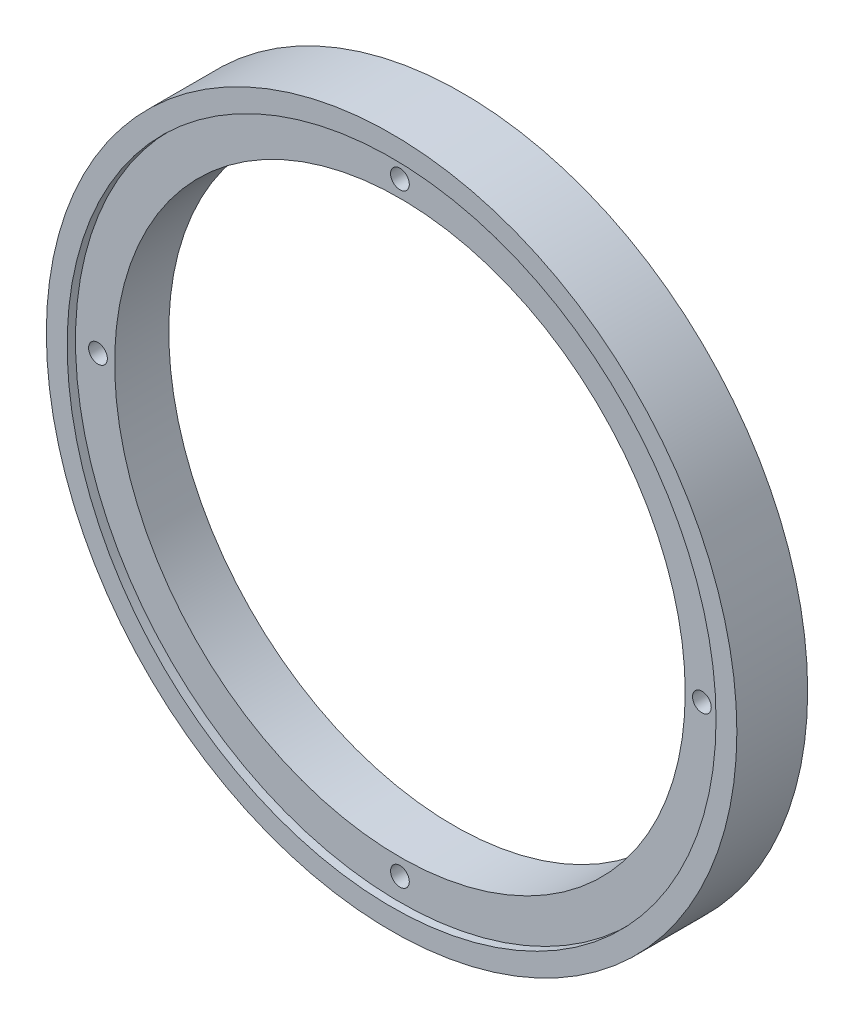
from build123d import *

# Parameters (mm, degrees)
ESQUISSE1_R             = 77.9
ESQUISSE1_R_2           = 2.25
ESQUISSE1_R_3           = 68.5
BOSS_EXTRU_1_DEPTH      = 13
BOSS_EXTRU_2_DEPTH      = 2
BOSS_EXTRU_2_DEPTH_BACK = 15
ESQUISSE2_R             = 82.9
ESQUISSE2_R_2           = 77.9


with BuildPart() as part:
    # Esquisse1 → Boss.-Extru.1 (new body)
    with BuildSketch(Plane.XY):
        Circle(ESQUISSE1_R)
        with Locations((0, -72.5)):
            Circle(ESQUISSE1_R_2, mode=Mode.SUBTRACT)
        with Locations((72.5, 0)):
            Circle(ESQUISSE1_R_2, mode=Mode.SUBTRACT)
        with Locations((-72.5, 0)):
            Circle(ESQUISSE1_R_2, mode=Mode.SUBTRACT)
        with Locations((0, 72.5)):
            Circle(ESQUISSE1_R_2, mode=Mode.SUBTRACT)
        Circle(ESQUISSE1_R_3, mode=Mode.SUBTRACT)
    extrude(amount=BOSS_EXTRU_1_DEPTH)

    # Esquisse2 → Boss.-Extru.2 (add, two sides: drawn at the far end of the back side and taken through both)
    with BuildSketch(Plane.XY.offset(13).offset(-BOSS_EXTRU_2_DEPTH_BACK)):
        Circle(ESQUISSE2_R)
        Circle(ESQUISSE2_R_2, mode=Mode.SUBTRACT)
    extrude(amount=BOSS_EXTRU_2_DEPTH + BOSS_EXTRU_2_DEPTH_BACK)


solid = part.part
